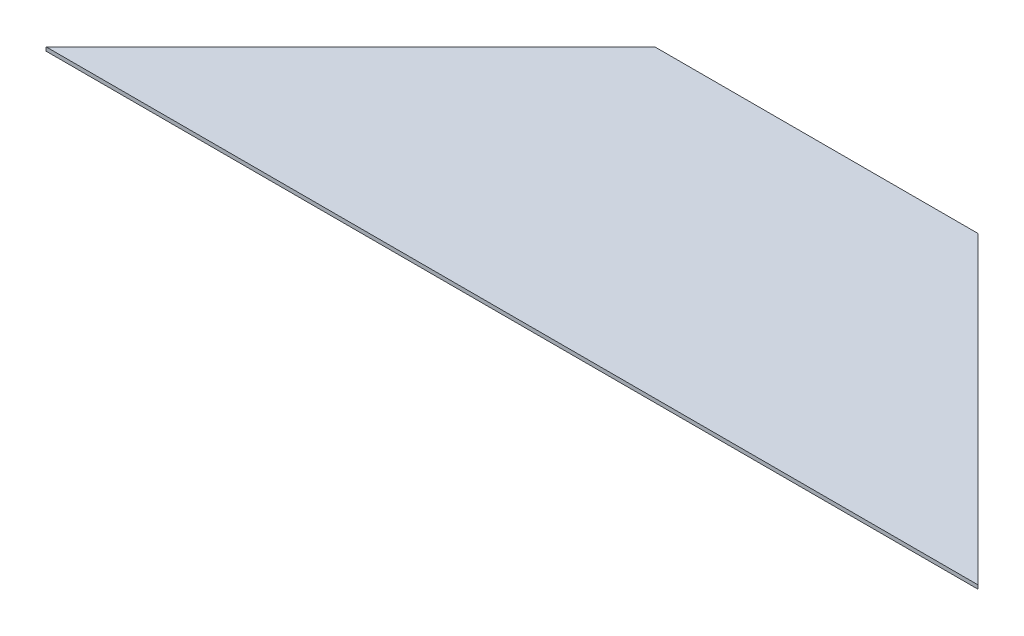
from build123d import *

# Parameters (mm, degrees)
EXTRUDE_1_DEPTH = 2


with BuildPart() as part:
    # 草图1 → 凸台-拉伸1 (new body)
    with BuildSketch(Plane(origin=(0, 0, 0), x_dir=(1, 0, 0), z_dir=(0, 1, 0))):
        Polygon((0, 0), (490, 0), (330, 160), (160, 160), align=None)
    extrude(amount=EXTRUDE_1_DEPTH)


solid = part.part
